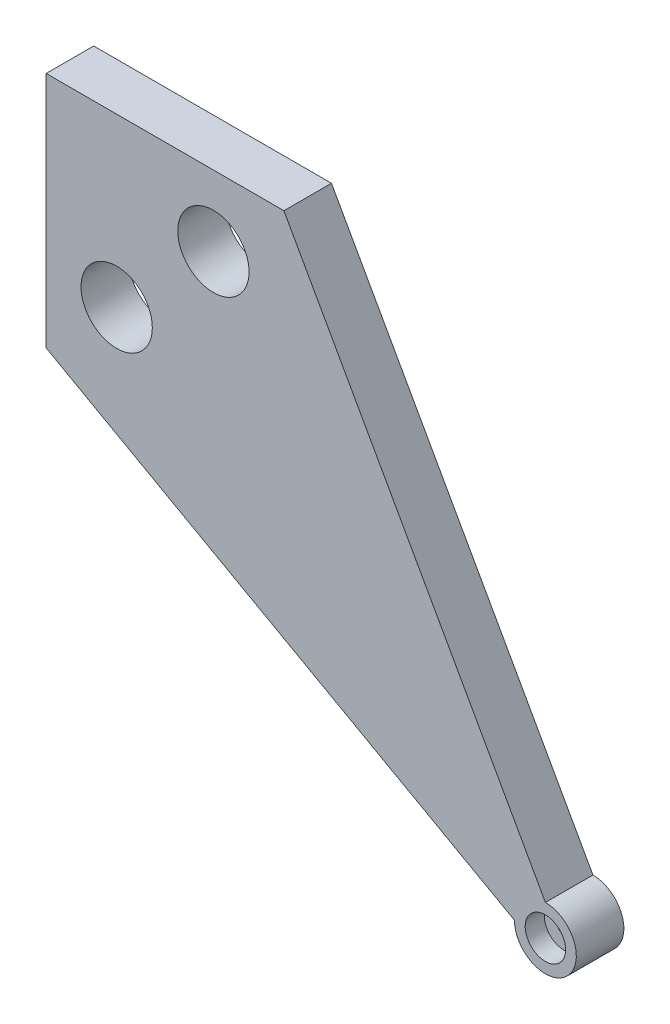
from build123d import *

# Parameters (mm, degrees)
RESSALTO_EXTRUS_O2_DEPTH = 5
ESBO_O4_R                = 4.25
CORTE_EXTRUS_O1_DEPTH    = 4
ESBO_O5_R                = 1.5
CORTE_EXTRUS_O2_DEPTH    = 7
ESBO_O6_R                = 7.5
CORTE_EXTRUS_O3_DEPTH    = 11


with BuildPart() as part:
    # Esboço3 → Ressalto-extrusão2 (new body, symmetric)
    with BuildSketch(Plane.XY):
        with BuildLine():
            Line((0, 50), (98.5, 105))
            ThreePointArc((98.5, 105), (109.596194078, 109.596194078), (105, 98.5))
            Line((105, 98.5), (50, 0))
            Line((50, 0), (0, 0))
            Line((0, 0), (0, 50))
        make_face()
    extrude(amount=RESSALTO_EXTRUS_O2_DEPTH, both=True)

    # Esboço4 → Corte-extrusão1 (cut)
    with BuildSketch(Plane.XY.offset(5)):
        with Locations((105, 105)):
            Circle(ESBO_O4_R)
    extrude(amount=-CORTE_EXTRUS_O1_DEPTH, mode=Mode.SUBTRACT)

    # Esboço5 → Corte-extrusão2 (cut, through all)
    with BuildSketch(Plane.XY.offset(1)):
        with Locations((105, 105)):
            Circle(ESBO_O5_R)
    extrude(amount=-CORTE_EXTRUS_O2_DEPTH, mode=Mode.SUBTRACT)

    # Esboço6 → Corte-extrusão3 (cut, through all)
    with BuildSketch(Plane.XY.offset(5)):
        with Locations((14.825558834, 35.174441166)):
            Circle(ESBO_O6_R)
        with Locations((35.174441166, 14.825558834)):
            Circle(ESBO_O6_R)
    extrude(amount=-CORTE_EXTRUS_O3_DEPTH, mode=Mode.SUBTRACT)


with BuildPart() as body_2:
    # Espelhar1: mirrored copy
    add(part.part.mirror(Plane(origin=(0, 0, 5), x_dir=(0, 0, 1), z_dir=(0, 1, 0))))


with BuildPart() as body_3:
    # Espelhar2: mirrored copy
    add(body_2.part.mirror(Plane(origin=(0, 0, 5), x_dir=(0, 0, 1), z_dir=(1, 0, 0))))


with BuildPart() as body_4:
    # Espelhar2 2: mirrored copy
    add(part.part.mirror(Plane(origin=(0, 0, 5), x_dir=(0, 0, 1), z_dir=(1, 0, 0))))


solid = body_2.part
